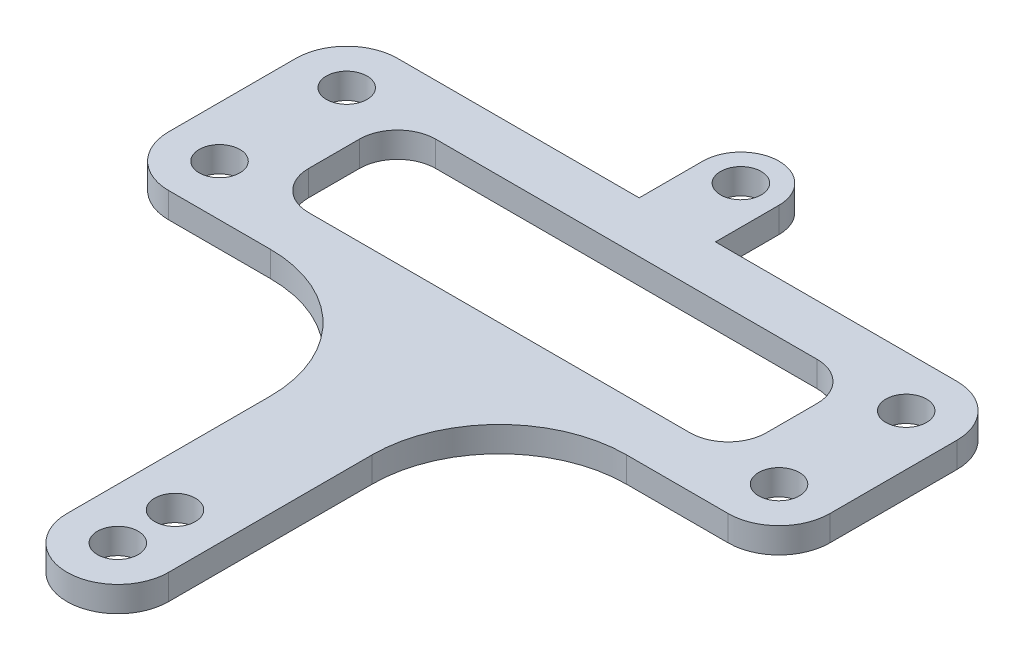
from build123d import *

# Parameters (mm, degrees)
SKETCH1_R            = 1.6
BOSS_EXTRUDE1_DEPTH  = 2
FILLET1_R            = 10
SKETCH2_R            = 4
BOSS_EXTRUDE3_DEPTH  = 2
SKETCH4_R            = 1.6
CUT_EXTRUDE2_DEPTH   = 4
CUT_EXTRUDE3_DEPTH   = 10
SKETCH6_R            = 3
SKETCH6_R_2          = 1.6
BOSS_EXTRUDE4_DEPTH  = 2
SKETCH7_R            = 1.6
CUT_EXTRUDE4_DEPTH   = 10
SKETCH8_W            = 36
SKETCH8_H            = 10
CUT_EXTRUDE6_DEPTH   = 9.5
FILLET3_R            = 3
SKETCH9_R            = 1.6
BOSS_EXTRUDE5_DEPTH  = 2
SKETCH10_R           = 1.6
BOSS_EXTRUDE6_DEPTH  = 2
SKETCH11_R           = 1.6
CUT_EXTRUDE7_DEPTH   = 10
BOSS_EXTRUDE7_DEPTH  = 2
SKETCH13_R           = 1.6
CUT_EXTRUDE9_DEPTH   = 5.5
BOSS_EXTRUDE8_DEPTH  = 2
SKETCH16_R           = 1.6
CUT_EXTRUDE10_DEPTH  = 10
SKETCH17_R           = 2.884899687
BOSS_EXTRUDE9_DEPTH  = 1
SKETCH18_R           = 1.6
BOSS_EXTRUDE10_DEPTH = 3
SKETCH19_R           = 1.6
SKETCH19_R_2         = 1.5
CUT_EXTRUDE11_DEPTH  = 2
SKETCH20_R           = 1.6
CUT_EXTRUDE12_DEPTH  = 10
SKETCH21_R           = 1.5
CUT_EXTRUDE13_DEPTH  = 8.5


with BuildPart() as part:
    # Sketch1 → Boss-Extrude1 (new body)
    with BuildSketch(Plane(origin=(0, 0, 0), x_dir=(1, 0, 0), z_dir=(0, 1, 0))):
        with BuildLine():
            Line((-4, -45), (-4, -30))
            Line((-4, -30), (-4, -19))
            Line((-4, -19), (-22, -19))
            ThreePointArc((-22, -19), (-24.828427125, -17.828427125), (-26, -15))
            Line((-26, -15), (-26, -5))
            ThreePointArc((-26, -5), (-24.828427125, -2.171572875), (-22, -1))
            Line((-22, -1), (-4, -1))
            Line((-4, -1), (-4, 0))
            ThreePointArc((-4, 0), (0, 4), (4, 0))
            Line((4, 0), (4, -1))
            Line((4, -1), (22, -1))
            ThreePointArc((22, -1), (24.828427125, -2.171572875), (26, -5))
            Line((26, -5), (26, -15))
            ThreePointArc((26, -15), (24.828427125, -17.828427125), (22, -19))
            Line((22, -19), (4, -19))
            Line((4, -19), (4, -30))
            Line((4, -30), (4, -45))
            ThreePointArc((4, -45), (0, -49), (-4, -45))
        make_face()
        with Locations((-22, -5)):
            Circle(SKETCH1_R, mode=Mode.SUBTRACT)
        Circle(SKETCH1_R, mode=Mode.SUBTRACT)
        with Locations((22, -5)):
            Circle(SKETCH1_R, mode=Mode.SUBTRACT)
        with Locations((22, -15)):
            Circle(SKETCH1_R, mode=Mode.SUBTRACT)
        with Locations((-22, -15)):
            Circle(SKETCH1_R, mode=Mode.SUBTRACT)
        with BuildLine():
            ThreePointArc((-1.6, -45), (0, -46.6), (1.6, -45))
            Line((1.6, -45), (1.6, -30))
            ThreePointArc((1.6, -30), (0, -28.4), (-1.6, -30))
            Line((-1.6, -30), (-1.6, -45))
        make_face(mode=Mode.SUBTRACT)
    extrude(amount=BOSS_EXTRUDE1_DEPTH)

    # Fillet1
    fillet1_edges = [part.edges().sort_by_distance(p)[0] for p in [
        (-4, 1, 19),
        (4, 1, 19),
    ]]
    fillet(fillet1_edges, radius=FILLET1_R)

    # Sketch2 → Boss-Extrude3 (add)
    with BuildSketch(Plane(origin=(0, 2, 0), x_dir=(1, 0, 0), z_dir=(0, 1, 0))):
        with BuildLine():
            ThreePointArc((-3.708099244, 1.5), (-2.797344782, 2.859171588), (-1.41859085, 3.74))
            ThreePointArc((-1.41859085, 3.74), (0, 4.6), (1.41859085, 3.74))
            ThreePointArc((1.41859085, 3.74), (2.797344782, 2.859171588), (3.708099244, 1.5))
            ThreePointArc((3.708099244, 1.5), (3.92634671, 2.23593095), (4, 3))
            ThreePointArc((4, 3), (0, 7), (-4, 3))
            ThreePointArc((-4, 3), (-3.92634671, 2.23593095), (-3.708099244, 1.5))
        make_face()
        with BuildLine():
            ThreePointArc((4, 3), (3.92634671, 2.23593095), (3.708099244, 1.5))
            ThreePointArc((3.708099244, 1.5), (3.92634671, 0.76406905), (4, 0))
            Line((4, 0), (4, 3))
        make_face()
        with BuildLine():
            ThreePointArc((-4, 0), (-3.92634671, 0.76406905), (-3.708099244, 1.5))
            ThreePointArc((-3.708099244, 1.5), (-3.92634671, 2.23593095), (-4, 3))
            Line((-4, 3), (-4, 0))
        make_face()
        Circle(SKETCH2_R)
    extrude(amount=-BOSS_EXTRUDE3_DEPTH)

    # Sketch4 → Cut-Extrude2 (cut)
    with BuildSketch(Plane(origin=(0, 2, 0), x_dir=(1, 0, 0), z_dir=(0, 1, 0))):
        with Locations((0, 3)):
            Circle(SKETCH4_R)
    extrude(amount=-CUT_EXTRUDE2_DEPTH, mode=Mode.SUBTRACT)

    # Sketch5 → Cut-Extrude3 (cut)
    with BuildSketch(Plane(origin=(0, 2, 0), x_dir=(1, 0, 0), z_dir=(0, 1, 0))):
        Polygon((-4, -1), (4, -1), (9.121752044, 12.8952039), (-11.957584595, 14.407484274), align=None)
    extrude(amount=-CUT_EXTRUDE3_DEPTH, mode=Mode.SUBTRACT)

    # Sketch6 → Boss-Extrude4 (add)
    with BuildSketch(Plane(origin=(0, 2, 0), x_dir=(1, 0, 0), z_dir=(0, 1, 0))):
        with Locations((0, -1)):
            Circle(SKETCH6_R)
        with Locations((0, -1)):
            Circle(SKETCH6_R_2, mode=Mode.SUBTRACT)
    extrude(amount=-BOSS_EXTRUDE4_DEPTH)

    # Sketch7 → Cut-Extrude4 (cut)
    with BuildSketch(Plane(origin=(0, 2, 0), x_dir=(1, 0, 0), z_dir=(0, 1, 0))):
        with Locations((0, -1)):
            Circle(SKETCH7_R)
    extrude(amount=-CUT_EXTRUDE4_DEPTH, mode=Mode.SUBTRACT)

    # Sketch8 → Cut-Extrude6 (cut)
    with BuildSketch(Plane(origin=(0, 2, 0), x_dir=(1, 0, 0), z_dir=(0, 1, 0))):
        with Locations((0, -10)):
            Rectangle(SKETCH8_W, SKETCH8_H)
    extrude(amount=-CUT_EXTRUDE6_DEPTH, mode=Mode.SUBTRACT)

    # Fillet3
    fillet3_edges = [part.edges().sort_by_distance(p)[0] for p in [
        (-18, 1, 5),
        (18, 1, 5),
        (18, 1, 15),
        (-18, 1, 15),
    ]]
    fillet(fillet3_edges, radius=FILLET3_R)

    # Sketch9 → Boss-Extrude5 (add)
    with BuildSketch(Plane(origin=(0, 2, 0), x_dir=(1, 0, 0), z_dir=(0, 1, 0))):
        with Locations((0, -1)):
            Circle(SKETCH9_R)
    extrude(amount=-BOSS_EXTRUDE5_DEPTH)

    # Sketch10 → Boss-Extrude6 (add)
    with BuildSketch(Plane(origin=(0, 2, 0), x_dir=(1, 0, 0), z_dir=(0, 1, 0))):
        with BuildLine():
            Line((3, -1), (3, 3))
            ThreePointArc((3, 3), (0, 6), (-3, 3))
            Line((-3, 3), (-3, -1))
            Line((-3, -1), (3, -1))
        make_face()
        with Locations((0, 3)):
            Circle(SKETCH10_R, mode=Mode.SUBTRACT)
    extrude(amount=-BOSS_EXTRUDE6_DEPTH)

    # Sketch11 → Cut-Extrude7 (cut)
    with BuildSketch(Plane(origin=(0, 2, 0), x_dir=(1, 0, 0), z_dir=(0, 1, 0))):
        with Locations((0, 3)):
            Circle(SKETCH11_R)
    extrude(amount=-CUT_EXTRUDE7_DEPTH, mode=Mode.SUBTRACT)

    # Sketch12 → Boss-Extrude7 (add)
    with BuildSketch(Plane(origin=(0, 2, 0), x_dir=(1, 0, 0), z_dir=(0, 1, 0))):
        with BuildLine():
            Line((-3, 3), (-3, 4))
            ThreePointArc((-3, 4), (0, 7), (3, 4))
            Line((3, 4), (3, 3))
            Line((3, 3), (2.828427125, 3))
            ThreePointArc((2.828427125, 3), (0, 1), (-2.828427125, 3))
            Line((-2.828427125, 3), (-3, 3))
        make_face()
    extrude(amount=-BOSS_EXTRUDE7_DEPTH)

    # Sketch13 → Cut-Extrude9 (cut)
    with BuildSketch(Plane(origin=(0, 2, 0), x_dir=(1, 0, 0), z_dir=(0, 1, 0))):
        with Locations((0, 4)):
            Circle(SKETCH13_R)
    extrude(amount=-CUT_EXTRUDE9_DEPTH, mode=Mode.SUBTRACT)

    # Sketch15 → Boss-Extrude8 (add)
    with BuildSketch(Plane(origin=(0, 2, 0), x_dir=(1, 0, 0), z_dir=(0, 1, 0))):
        with BuildLine():
            Line((-4, -45), (-4, -23.953750057))
            Line((-4, -23.953750057), (4, -23.953750057))
            Line((4, -23.953750057), (4, -45))
            ThreePointArc((4, -45), (0, -49), (-4, -45))
        make_face()
    extrude(amount=-BOSS_EXTRUDE8_DEPTH)

    # Sketch16 → Cut-Extrude10 (cut)
    with BuildSketch(Plane(origin=(0, 2, 0), x_dir=(1, 0, 0), z_dir=(0, 1, 0))):
        with Locations((0, -45)):
            Circle(SKETCH16_R)
        with Locations((0, -36)):
            Circle(SKETCH16_R)
    extrude(amount=-CUT_EXTRUDE10_DEPTH, mode=Mode.SUBTRACT)

    # Sketch17 → Boss-Extrude9 (add)
    with BuildSketch(Plane(origin=(0, 2, 0), x_dir=(1, 0, 0), z_dir=(0, 1, 0))):
        with Locations((0, -36)):
            Circle(SKETCH17_R)
    extrude(amount=-BOSS_EXTRUDE9_DEPTH)

    # Sketch18 → Boss-Extrude10 (add)
    with BuildSketch(Plane(origin=(0, 1, 0), x_dir=(-1, 0, 0), z_dir=(0, -1, 0))):
        with Locations((0, -36)):
            Circle(SKETCH18_R)
    extrude(amount=BOSS_EXTRUDE10_DEPTH)

    # Sketch19 → Cut-Extrude11 (cut)
    with BuildSketch(Plane(origin=(0, -2, 0), x_dir=(-1, 0, 0), z_dir=(0, -1, 0))):
        with Locations((0, -36)):
            Circle(SKETCH19_R)
        with Locations((0, -36)):
            Circle(SKETCH19_R_2, mode=Mode.SUBTRACT)
    extrude(amount=-CUT_EXTRUDE11_DEPTH, mode=Mode.SUBTRACT)

    # Sketch20 → Cut-Extrude12 (cut)
    with BuildSketch(Plane(origin=(0, 0, 0), x_dir=(-1, 0, 0), z_dir=(0, -1, 0))):
        with Locations((0, -40.5)):
            Circle(SKETCH20_R)
    extrude(amount=-CUT_EXTRUDE12_DEPTH, mode=Mode.SUBTRACT)

    # Sketch21 → Cut-Extrude13 (cut)
    with BuildSketch(Plane(origin=(0, 0, 0), x_dir=(-1, 0, 0), z_dir=(0, -1, 0))):
        with Locations((0, -36)):
            Circle(SKETCH21_R)
    extrude(amount=CUT_EXTRUDE13_DEPTH, mode=Mode.SUBTRACT)


solid = part.part
